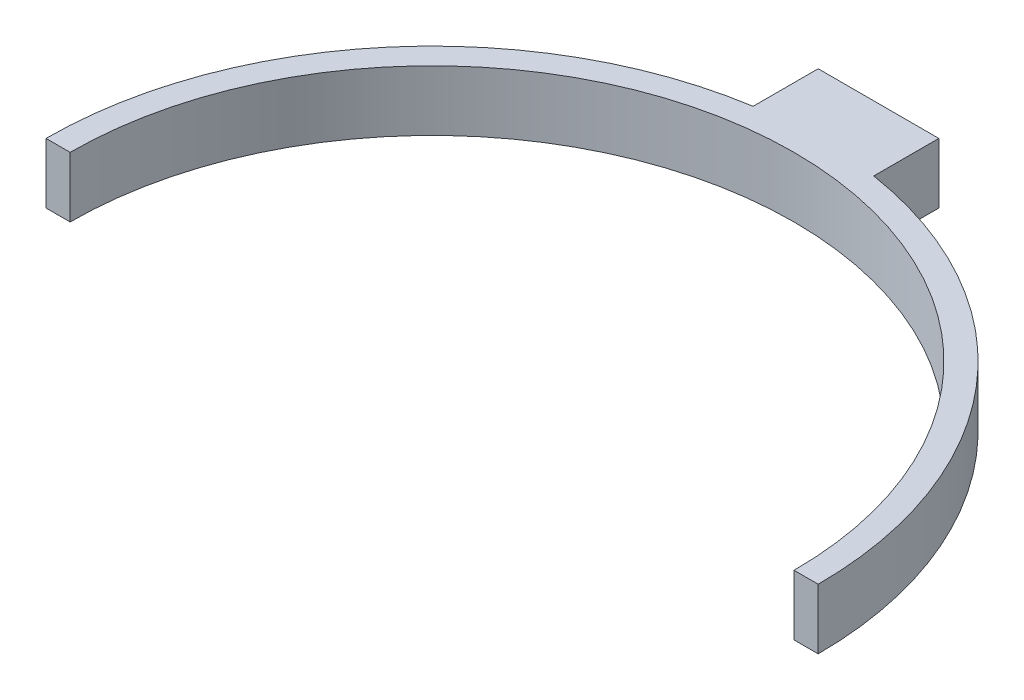
from build123d import *

# Parameters (mm, degrees)
EXTRUDE_1_DEPTH = 5
EXTRUDE_2_DEPTH = 5


with BuildPart() as part:
    # 草图1 → 凸台-拉伸1 (new body)
    with BuildSketch(Plane(origin=(0, 0, 0), x_dir=(1, 0, 0), z_dir=(0, 1, 0))):
        with BuildLine():
            Line((-32, 0), (-30, 0))
            ThreePointArc((-30, 0), (0, 30), (30, 0))
            Line((30, 0), (32, 0))
            ThreePointArc((32, 0), (0, 32), (-32, 0))
        make_face()
    extrude(amount=EXTRUDE_1_DEPTH)

    # 草图2 → 凸台-拉伸2 (add)
    with BuildSketch(Plane(origin=(0, 0, 0), x_dir=(1, 0, 0), z_dir=(0, 1, 0))):
        Polygon((5, 37), (0, 37), (-5, 37), (-5, 30.465276436), (5, 30.465276436), align=None)
    extrude(amount=EXTRUDE_2_DEPTH)


solid = part.part
